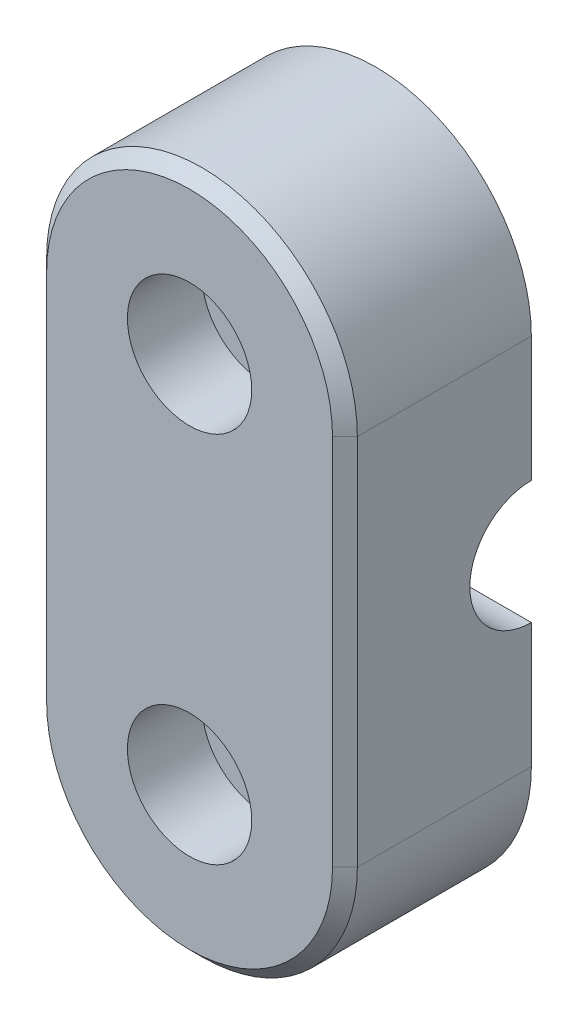
from build123d import *

# Parameters (mm, degrees)
SKETCH1_R           = 3.25
BOSS_EXTRUDE1_DEPTH = 15
CUT_EXTRUDE1_REACH  = 27
SKETCH2_R           = 4.95
CHAMFER1_SIZE       = 1
SKETCH3_R           = 5
CUT_EXTRUDE2_DEPTH  = 6
BOSS_EXTRUDE2_DEPTH = 0.95


with BuildPart() as part:
    # Sketch1 → Boss-Extrude1 (new body)
    with BuildSketch(Plane.XY):
        with BuildLine():
            Line((-12.5, 15), (-12.5, -15))
            ThreePointArc((-12.5, -15), (0, -27.5), (12.5, -15))
            Line((12.5, -15), (12.5, 15))
            ThreePointArc((12.5, 15), (0, 27.5), (-12.5, 15))
        make_face()
        with Locations((0, 15)):
            Circle(SKETCH1_R, mode=Mode.SUBTRACT)
        with Locations((0, -15)):
            Circle(SKETCH1_R, mode=Mode.SUBTRACT)
    extrude(amount=BOSS_EXTRUDE1_DEPTH)

    # Sketch2 → Cut-Extrude1 (cut, up to next)
    with BuildSketch(Plane(origin=(12.5, 0, 0), x_dir=(0, 0, -1), z_dir=(1, 0, 0)), mode=Mode.PRIVATE) as cut_extrude1_sk1:
        Circle(SKETCH2_R)
    cut_extrude1_tool1 = extrude(cut_extrude1_sk1.sketch, amount=-CUT_EXTRUDE1_REACH, mode=Mode.PRIVATE) & part.part
    add(cut_extrude1_tool1.solids().sort_by_distance((12.5, 0, 0))[0], mode=Mode.SUBTRACT)

    # Chamfer1
    chamfer1_edges = [part.edges().sort_by_distance(p)[0] for p in [
        (-12.5, 0, 15),
        (0, -27.5, 15),
        (12.5, 0, 15),
        (0, 27.5, 15),
    ]]
    chamfer(chamfer1_edges, length=CHAMFER1_SIZE)

    # Sketch3 → Cut-Extrude2 (cut)
    with BuildSketch(Plane.XY.offset(15)):
        with Locations((0, 15)):
            Circle(SKETCH3_R)
        with Locations((0, -15)):
            Circle(SKETCH3_R)
    extrude(amount=-CUT_EXTRUDE2_DEPTH, mode=Mode.SUBTRACT)

    # Sketch5 → Boss-Extrude2 (add, symmetric)
    with BuildSketch(Plane(origin=(0, 0, 0), x_dir=(0, 0, -1), z_dir=(1, 0, 0))):
        with BuildLine():
            Line((0, 4.5), (0, 4.95))
            ThreePointArc((0, 4.95), (-4.95, 0), (0, -4.95))
            Line((0, -4.95), (0, -4.5))
            ThreePointArc((0, -4.5), (-4.5, 0), (0, 4.5))
        make_face()
    extrude(amount=BOSS_EXTRUDE2_DEPTH, both=True)


solid = part.part
